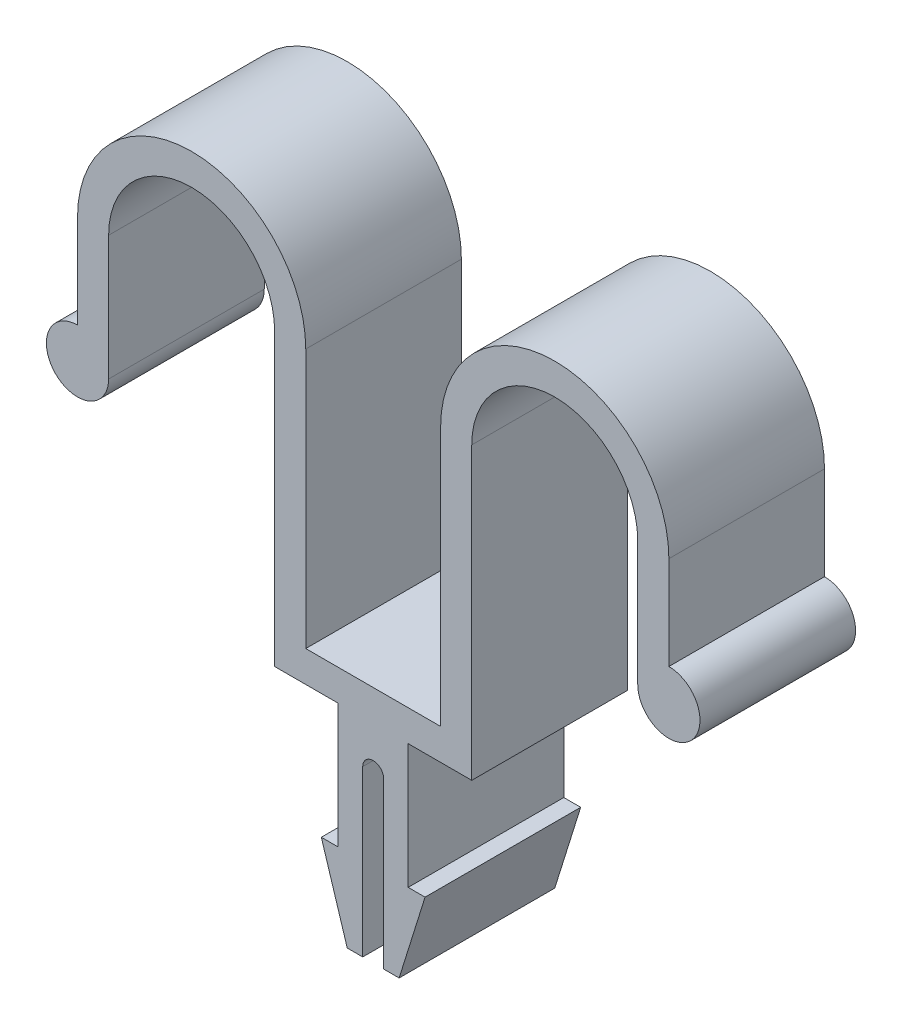
from build123d import *

# Parameters (mm, degrees)
BOSS_EXTRUDE1_DEPTH = 15


with BuildPart() as part:
    # Sketch1 → Boss-Extrude1 (new body)
    with BuildSketch(Plane.XY):
        with BuildLine():
            Line((0, 3), (0, 12))
            ThreePointArc((0, 12), (11, 23), (22, 12))
            Line((22, 12), (22, -13))
            Line((22, -13), (35, -13))
            Line((35, -13), (35, 12))
            ThreePointArc((35, 12), (46, 23), (57, 12))
            Line((57, 12), (57, 3))
            ThreePointArc((57, 3), (59.121320344, -2.121320344), (54, 0))
            Line((54, 0), (54, 12))
            ThreePointArc((54, 12), (46, 20), (38, 12))
            Line((38, 12), (38, -16))
            Line((38, -16), (31.871401461, -16))
            Line((31.871401461, -16), (31.871401461, -28))
            Line((31.871401461, -28), (33.5, -28))
            Line((33.5, -28), (31, -36))
            Line((31, -36), (29.507974066, -36))
            Line((29.507974066, -36), (29.507974066, -20.105540997))
            ThreePointArc((29.507974066, -20.105540997), (29.212255946, -19.395620555), (28.5, -19.10557279))
            ThreePointArc((28.5, -19.10557279), (27.787744054, -19.395620555), (27.492025934, -20.105540997))
            Line((27.492025934, -20.105540997), (27.492025934, -36))
            Line((27.492025934, -36), (26, -36))
            Line((26, -36), (23.5, -28))
            Line((23.5, -28), (25.128598539, -28))
            Line((25.128598539, -28), (25.128598539, -16))
            Line((25.128598539, -16), (19, -16))
            Line((19, -16), (19, 12))
            ThreePointArc((19, 12), (11, 20), (3, 12))
            Line((3, 12), (3, 0))
            ThreePointArc((3, 0), (-2.121320344, -2.121320344), (0, 3))
        make_face()
    extrude(amount=BOSS_EXTRUDE1_DEPTH)


solid = part.part
